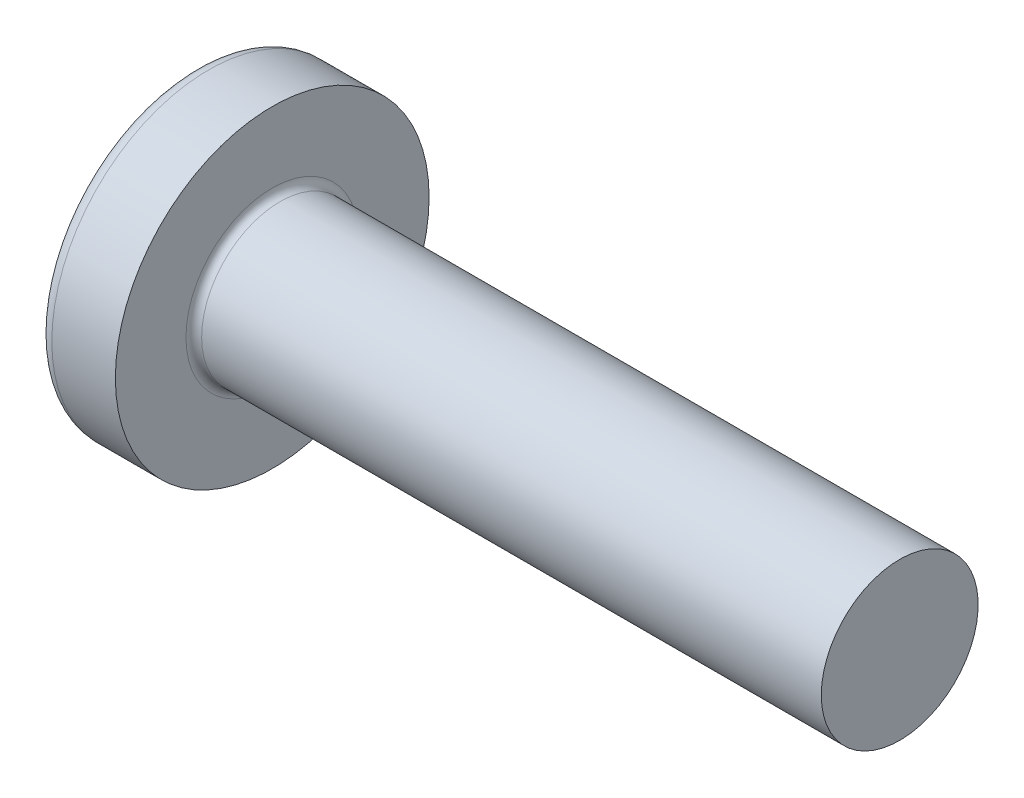
from build123d import *

# Parameters (mm, degrees)
FILLET1_R    = 0.1
SKETCH3_W    = 0.48
SKETCH3_H    = 2.1
SKETCH4_W    = 0.48
SKETCH4_H    = 0.684028282
RECPAT_COUNT = 2
RECPAT_ANGLE = 90


with BuildPart() as part:
    # BodySke → Base-Revolve (revolve)
    with BuildSketch(Plane.XY):
        with BuildLine():
            Line((1.6, 1), (1.6, 2))
            Line((1.6, 2), (0.790020747, 2))
            ThreePointArc((0.790020747, 2), (0.709789294, 1.981130115), (0.646379599, 1.928476821))
            ThreePointArc((0.646379599, 1.928476821), (0.165895084, 1.016959861), (0, 0))
            Line((0, 0), (9.6, 0))
            Line((9.6, 0), (9.6, 1))
            Line((9.6, 1), (1.6, 1))
        make_face()
    revolve(axis=Axis((-25.4, 0, 0), (1, 0, 0)))

    # Fillet1
    fillet1_edges = [part.edges().sort_by_distance(p)[0] for p in [
        (1.6, -1, 0),
    ]]
    fillet(fillet1_edges, radius=FILLET1_R)

    # Sketch3 → Recess section 0
    with BuildSketch(Plane(origin=(0, 0, 0), x_dir=(0, 0, -1), z_dir=(1, 0, 0))):
        Rectangle(SKETCH3_W, SKETCH3_H)
    # Sketch4 → Recess section 1
    with BuildSketch(Plane(origin=(1.42, 0, 0), x_dir=(0, 0, -1), z_dir=(1, 0, 0))):
        Rectangle(SKETCH4_W, SKETCH4_H)
    recess = loft(mode=Mode.SUBTRACT)

    # RecPat: Recess ×2 about axis
    recpat_axis = Axis((0, 0, 0), (1, 0, 0))
    for i in range(1, RECPAT_COUNT):
        add(recess.rotate(recpat_axis, i * RECPAT_ANGLE / (RECPAT_COUNT - 1)), mode=Mode.SUBTRACT)

    # RecCorSke → RecessCore (revolve, cut)
    with BuildSketch(Plane.XY):
        Polygon((0, 0), (0, 0.454796073), (1.42, 0.3555), (1.535508952, 0), align=None)
    revolve(axis=Axis((-3.175, 0, 0), (1, 0, 0)), mode=Mode.SUBTRACT)


solid = part.part
